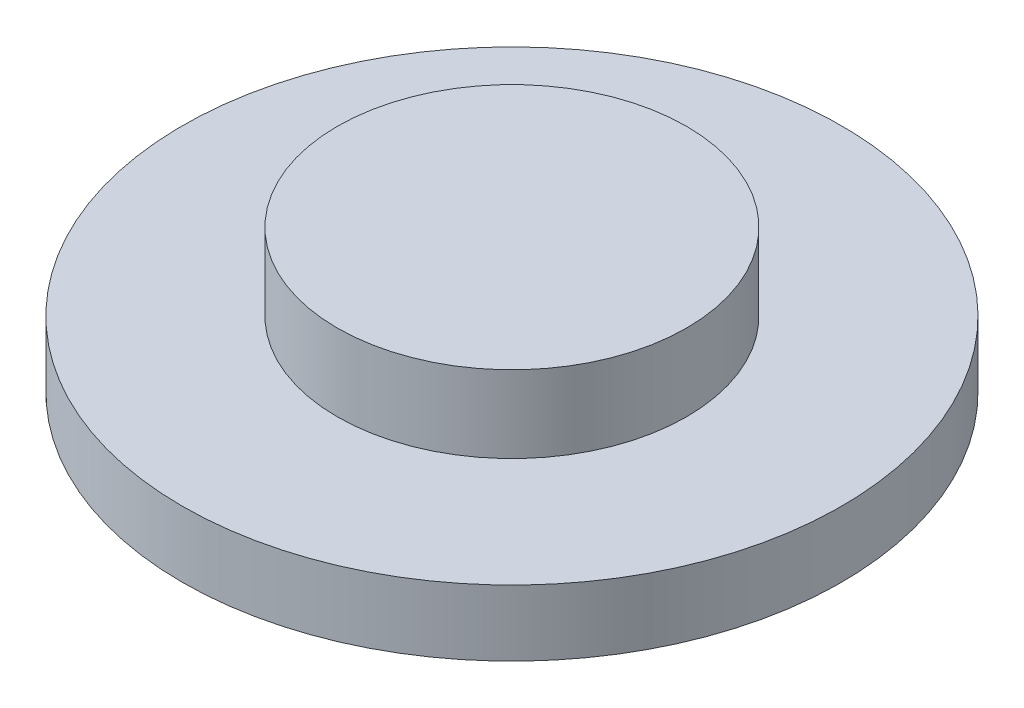
from build123d import *

# Parameters (mm, degrees)
SKETCH_1_R      = 15
EXTRUDE_1_DEPTH = 3
SKETCH_2_R      = 7.95
EXTRUDE_2_DEPTH = 3.5


with BuildPart() as part:
    # 草图1 → 凸台-拉伸1 (new body)
    with BuildSketch(Plane(origin=(0, 0, 0), x_dir=(1, 0, 0), z_dir=(0, 1, 0))):
        Circle(SKETCH_1_R)
    extrude(amount=EXTRUDE_1_DEPTH)

    # 草图2 → 凸台-拉伸2 (add)
    with BuildSketch(Plane(origin=(0, 3, 0), x_dir=(1, 0, 0), z_dir=(0, 1, 0))):
        Circle(SKETCH_2_R)
    extrude(amount=EXTRUDE_2_DEPTH)


solid = part.part
